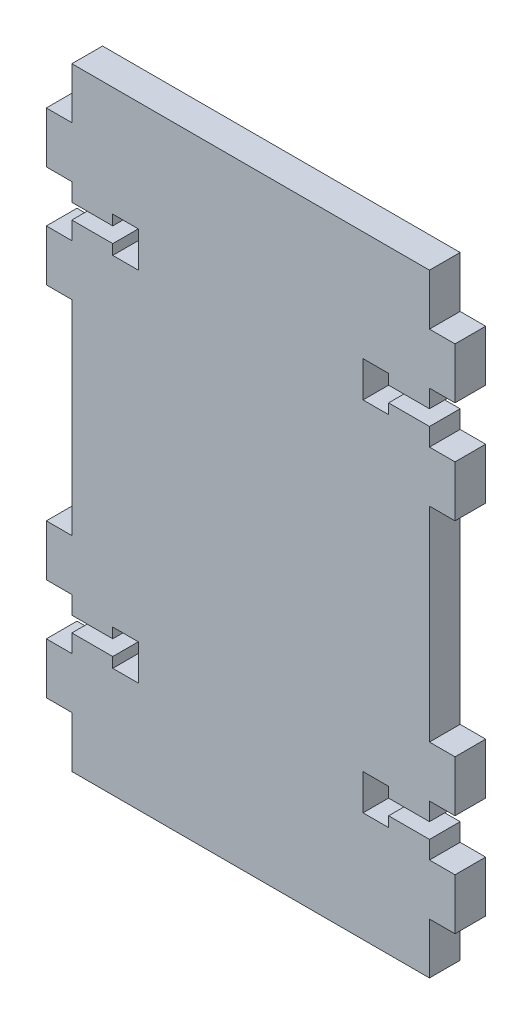
from build123d import *

# Parameters (mm, degrees)
RESSALTO_EXTRUS_O1_DEPTH = 6


with BuildPart() as part:
    # Model → Ressalto-extrusão1 (new body)
    with BuildSketch(Plane.XY):
        Polygon((0, -10), (0, 0), (-70, 0), (-70, -10), (-75, -10), (-75, -20), (-70, -20), (-70, -23.5), (-62, -23.5), (-62, -21.5), (-57, -21.5), (-57, -28.5), (-62, -28.5), (-62, -26.5), (-70, -26.5), (-70, -30), (-75, -30), (-75, -40), (-70, -40), (-70, -80), (-75, -80), (-75, -90), (-70, -90), (-70, -93.5), (-62, -93.5), (-62, -91.5), (-57, -91.5), (-57, -98.5), (-62, -98.5), (-62, -96.5), (-70, -96.5), (-70, -100), (-75, -100), (-75, -110), (-70, -110), (-70, -120), (0, -120), (0, -110), (5, -110), (5, -100), (0, -100), (0, -96.5), (-8, -96.5), (-8, -98.5), (-13, -98.5), (-13, -91.5), (-8, -91.5), (-8, -93.5), (0, -93.5), (0, -90), (5, -90), (5, -80), (0, -80), (0, -40), (5, -40), (5, -30), (0, -30), (0, -26.5), (-8, -26.5), (-8, -28.5), (-13, -28.5), (-13, -21.5), (-8, -21.5), (-8, -23.5), (0, -23.5), (0, -20), (5, -20), (5, -10), align=None)
    extrude(amount=RESSALTO_EXTRUS_O1_DEPTH)


solid = part.part
